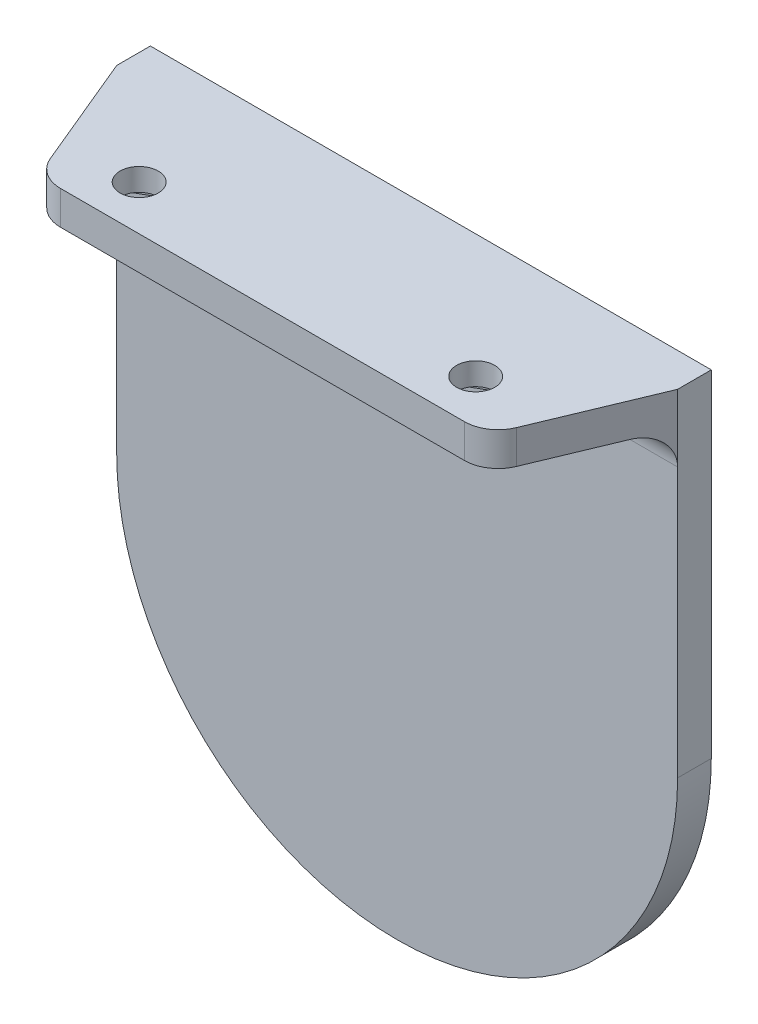
from build123d import *

# Parameters (mm, degrees)
EXTRUDE_1_DEPTH             = 3
EXTRUDE_2_DEPTH             = 3
CUT_EXTRUDE_1_DEPTH         = 1
CUT_EXTRUDE_2_DEPTH         = 1
HOLE_WIZARD_3_4_3_4_1_D     = 3.4
HOLE_WIZARD_3_4_3_4_1_DEPTH = 55
FILLET_1_R                  = 3


with BuildPart() as part:
    # 草图1 → 凸台-拉伸1 (new body)
    with BuildSketch(Plane(origin=(0, 177.5, 0), x_dir=(1, 0, 0), z_dir=(0, 1, 0))):
        Polygon((920, -15), (925, -3), (875, -3), (880, -15), align=None)
    extrude(amount=-EXTRUDE_1_DEPTH)

    # 草图2 → 凸台-拉伸2 (add)
    with BuildSketch(Plane(origin=(0, 0, 3), x_dir=(-1, 0, 0), z_dir=(0, 0, -1))):
        with BuildLine():
            Line((-925, 147.5), (-925, 177.5))
            Line((-925, 177.5), (-875, 177.5))
            Line((-875, 177.5), (-875, 147.5))
            ThreePointArc((-875, 147.5), (-900, 122.5), (-925, 147.5))
        make_face()
    extrude(amount=EXTRUDE_2_DEPTH)

    # 草图3 → 切除-拉伸1 (cut)
    with BuildSketch(Plane.XZ.offset(-174.5)):
        Polygon((912.142116168, 12.65), (912.142116168, 9.35), (915, 7.7), (917.857883832, 9.35), (917.857883832, 12.65), (915, 14.3), align=None)
    extrude(amount=-CUT_EXTRUDE_1_DEPTH, mode=Mode.SUBTRACT)

    # 草图4 → 切除-拉伸2 (cut)
    with BuildSketch(Plane.XZ.offset(-174.5)):
        Polygon((882.142116168, 9.35), (885, 7.7), (887.857883832, 9.35), (887.857883832, 12.65), (885, 14.3), (882.142116168, 12.65), align=None)
    extrude(amount=-CUT_EXTRUDE_2_DEPTH, mode=Mode.SUBTRACT)

    # Ø3.4 (3.4) 直径孔1
    with Locations(Plane(origin=(0, 177.5, 0), x_dir=(1, 0, 0), z_dir=(0, 1, 0))):
        with Locations((885, -11), (915, -11)):
            Hole(HOLE_WIZARD_3_4_3_4_1_D / 2, depth=HOLE_WIZARD_3_4_3_4_1_DEPTH)

    # 圆角1
    fillet_1_edges = [part.edges().sort_by_distance(p)[0] for p in [
        (900, 174.5, 3),
        (880, 176, 15),
        (920, 176, 15),
    ]]
    fillet(fillet_1_edges, radius=FILLET_1_R)


solid = part.part
